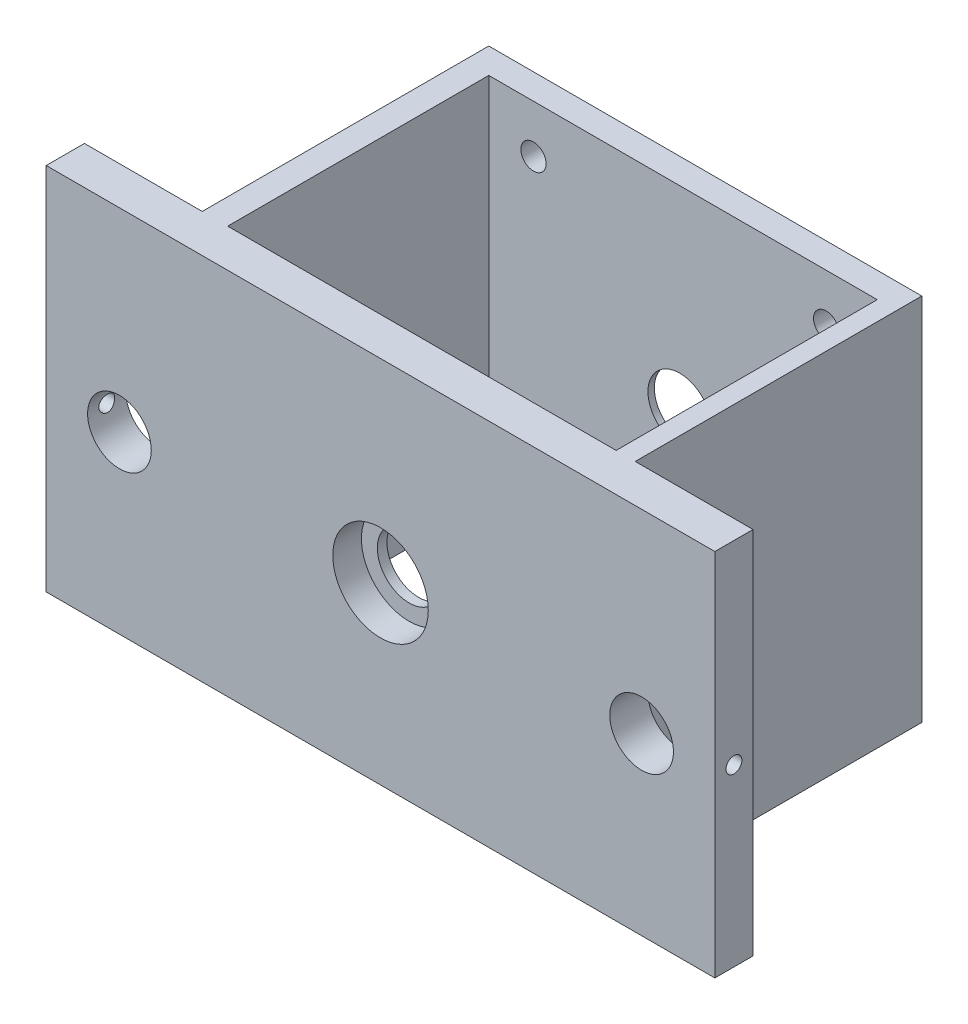
from build123d import *

# Parameters (mm, degrees)
SKETCH1_W                 = 210
SKETCH1_H                 = 12
BOSS_EXTRUDE1_DEPTH       = 116
SKETCH2_R                 = 10
CUT_EXTRUDE1_DEPTH        = 241.208242989
F_5_0MM_DOWEL_HOLE1_D     = 5
F_5_0MM_DOWEL_HOLE1_DEPTH = 25
F_5_0MM_DOWEL_HOLE1_TIP   = 1.502151548
F_5_0MM_DOWEL_HOLE2_D     = 5
F_5_0MM_DOWEL_HOLE2_DEPTH = 25
F_5_0MM_DOWEL_HOLE2_TIP   = 1.502151548
F_5_0MM_DOWEL_HOLE3_D     = 5
F_5_0MM_DOWEL_HOLE3_DEPTH = 25
F_5_0MM_DOWEL_HOLE3_TIP   = 1.502151548
SKETCH11_W                = 8
SKETCH11_H                = 116
SKETCH11_W_2              = 6
BOSS_EXTRUDE2_DEPTH       = 90
BOSS_EXTRUDE4_REACH       = 229.484
SKETCH12_W                = 8
SKETCH12_H                = 116
SKETCH7_R                 = 10
CUT_EXTRUDE3_DEPTH        = 261.691388508
SKETCH13_R                = 47.5
CUT_EXTRUDE4_DEPTH        = 6
CIRPATTERN1_COUNT         = 4
SKETCH16_R                = 15
CUT_EXTRUDE5_DEPTH        = 9


with BuildPart() as part:
    # Sketch1 → Boss-Extrude1 (new body)
    with BuildSketch(Plane(origin=(0, 0, 0), x_dir=(1, 0, 0), z_dir=(0, 1, 0))):
        with Locations((105, 6)):
            Rectangle(SKETCH1_W, SKETCH1_H)
    extrude(amount=BOSS_EXTRUDE1_DEPTH)

    # Sketch2 → Cut-Extrude1 (cut, through all)
    with BuildSketch(Plane.XY):
        with Locations((23, 55)):
            Circle(SKETCH2_R)
        with Locations((187, 55)):
            Circle(SKETCH2_R)
    extrude(amount=-CUT_EXTRUDE1_DEPTH, mode=Mode.SUBTRACT)

    # Ø5.0mm Dowel Hole1
    with Locations(Plane.ZY):
        with Locations((-6, 55)):
            Hole(F_5_0MM_DOWEL_HOLE1_D / 2, depth=F_5_0MM_DOWEL_HOLE1_DEPTH)
            with Locations((0, 0, -(F_5_0MM_DOWEL_HOLE1_DEPTH + F_5_0MM_DOWEL_HOLE1_TIP / 2))):  # 118° drill point
                Cone(0, F_5_0MM_DOWEL_HOLE1_D / 2, F_5_0MM_DOWEL_HOLE1_TIP, mode=Mode.SUBTRACT)

    # Ø5.0mm Dowel Hole2
    with Locations(Plane(origin=(210, 0, 0), x_dir=(0, 0, -1), z_dir=(1, 0, 0))):
        with Locations((6, 55)):
            Hole(F_5_0MM_DOWEL_HOLE2_D / 2, depth=F_5_0MM_DOWEL_HOLE2_DEPTH)
            with Locations((0, 0, -(F_5_0MM_DOWEL_HOLE2_DEPTH + F_5_0MM_DOWEL_HOLE2_TIP / 2))):  # 118° drill point
                Cone(0, F_5_0MM_DOWEL_HOLE2_D / 2, F_5_0MM_DOWEL_HOLE2_TIP, mode=Mode.SUBTRACT)

    # Ø5.0mm Dowel Hole3
    with Locations(Plane(origin=(0, 0, 0), x_dir=(-1, 0, 0), z_dir=(0, -1, 0))):
        with Locations((-25, 6), (-105, 6), (-185, 6)):
            Hole(F_5_0MM_DOWEL_HOLE3_D / 2, depth=F_5_0MM_DOWEL_HOLE3_DEPTH)
            with Locations((0, 0, -(F_5_0MM_DOWEL_HOLE3_DEPTH + F_5_0MM_DOWEL_HOLE3_TIP / 2))):  # 118° drill point
                Cone(0, F_5_0MM_DOWEL_HOLE3_D / 2, F_5_0MM_DOWEL_HOLE3_TIP, mode=Mode.SUBTRACT)

    # Sketch11 → Boss-Extrude2 (add)
    with BuildSketch(Plane(origin=(0, 0, -12), x_dir=(-1, 0, 0), z_dir=(0, 0, -1))):
        with Locations((-41, 58)):
            Rectangle(SKETCH11_W, SKETCH11_H)
        with Locations((-170, 58)):
            Rectangle(SKETCH11_W_2, SKETCH11_H)
    extrude(amount=BOSS_EXTRUDE2_DEPTH)

    # Sketch12 → Boss-Extrude4 (add, up to next)
    with BuildSketch(Plane.ZY.offset(-167), mode=Mode.PRIVATE) as boss_extrude4_sk1:
        with Locations((-98, 58)):
            Rectangle(SKETCH12_W, SKETCH12_H)
    boss_extrude4_tool1 = extrude(boss_extrude4_sk1.sketch, amount=BOSS_EXTRUDE4_REACH, mode=Mode.PRIVATE) - part.part
    add(boss_extrude4_tool1.solids().sort_by_distance((167, 58, -98))[0])

    # Sketch7 → Cut-Extrude3 (cut, through all)
    with BuildSketch(Plane.XY):
        with Locations((105, 55)):
            Circle(SKETCH7_R)
    extrude(amount=-CUT_EXTRUDE3_DEPTH, mode=Mode.SUBTRACT)

    # Sketch13 → Cut-Extrude4 (cut)
    with BuildSketch(Plane(origin=(0, 0, -102), x_dir=(-1, 0, 0), z_dir=(0, 0, -1))):
        with Locations((-105, 55)):
            Circle(SKETCH13_R)
    extrude(amount=-CUT_EXTRUDE4_DEPTH, mode=Mode.SUBTRACT)

    # Sketch14 → 5_16 _0.3125_ Diameter Hole1 (revolve, cut)
    with BuildSketch(Plane(origin=(150.961940777, 100.961940777, -102), x_dir=(0, 1, 0), z_dir=(1, 0, 0))):
        Polygon((0, 0), (0, 14.384665582), (3.96875, 12), (3.96875, 0), align=None)
    f_5_16_0_3125_diameter_hole1 = revolve(axis=Axis((150.961940777, 100.961940777, -108.35), (0, 0, 1)), mode=Mode.SUBTRACT)

    # CirPattern1: 5_16 _0.3125_ Diameter Hole1 ×4 about axis
    cirpattern1_axis = Axis((105, 55, -96), (0, 0, 1))
    for i in range(1, CIRPATTERN1_COUNT):
        add(f_5_16_0_3125_diameter_hole1.rotate(cirpattern1_axis, i * 360 / CIRPATTERN1_COUNT), mode=Mode.SUBTRACT)

    # Sketch16 → Cut-Extrude5 (cut)
    with BuildSketch(Plane.XY):
        with Locations((105, 55)):
            Circle(SKETCH16_R)
    extrude(amount=-CUT_EXTRUDE5_DEPTH, mode=Mode.SUBTRACT)


solid = part.part
